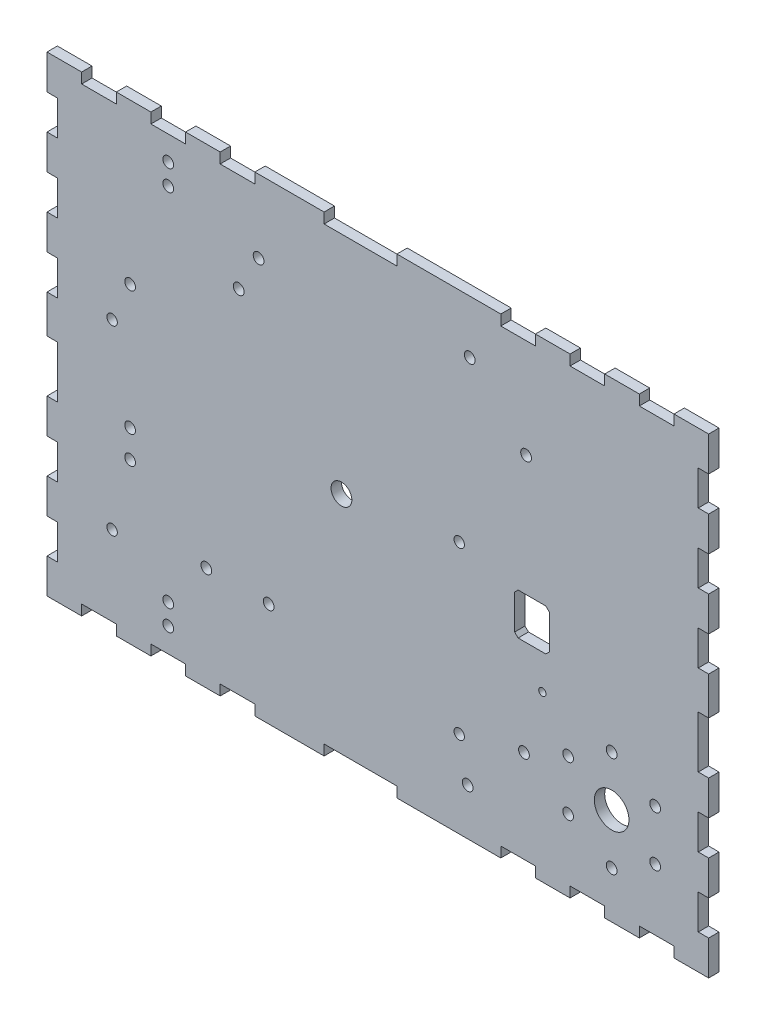
from build123d import *

# Parameters (mm, degrees)
SKETCH2_W           = 191
SKETCH2_H           = 136
SKETCH2_R           = 1.55
SKETCH2_R_2         = 1.549999948
SKETCH2_R_3         = 1.5
BOSS_EXTRUDE1_DEPTH = 3
CUT_EXTRUDE1_REACH  = 236.491
SKETCH3_W           = 10
SKETCH3_H           = 3
SKETCH3_W_2         = 21
CUT_EXTRUDE2_REACH  = 236.491
SKETCH4_W           = 3
SKETCH4_H           = 10
SKETCH4_H_2         = 15
CUT_EXTRUDE3_REACH  = 236.491
SKETCH8_R           = 5
CUT_EXTRUDE4_REACH  = 236.491
SKETCH9_R           = 3
CUT_EXTRUDE5_REACH  = 236.491
SKETCH10_R          = 1.55
CUT_EXTRUDE6_REACH  = 236.491
SKETCH11_R          = 1.05
SKETCH11_W          = 10
SKETCH11_H          = 12
CHAMFER1_SIZE       = 1


with BuildPart() as part:
    # Sketch2 → Boss-Extrude1 (new body)
    with BuildSketch(Plane.XY):
        with Locations((95.5, 68)):
            Rectangle(SKETCH2_W, SKETCH2_H)
        with Locations((35, 16)):
            Circle(SKETCH2_R, mode=Mode.SUBTRACT)
        with Locations((35, 10)):
            Circle(SKETCH2_R, mode=Mode.SUBTRACT)
        with Locations((24, 46.069195574)):
            Circle(SKETCH2_R, mode=Mode.SUBTRACT)
        with Locations((24, 54.069195574)):
            Circle(SKETCH2_R, mode=Mode.SUBTRACT)
        with Locations((24, 89.930804426)):
            Circle(SKETCH2_R, mode=Mode.SUBTRACT)
        with Locations((35, 120)):
            Circle(SKETCH2_R, mode=Mode.SUBTRACT)
        with Locations((35, 126)):
            Circle(SKETCH2_R, mode=Mode.SUBTRACT)
        with Locations((175.557368355, 35.25)):
            Circle(SKETCH2_R_2, mode=Mode.SUBTRACT)
        with Locations((163, 42.5)):
            Circle(SKETCH2_R_2, mode=Mode.SUBTRACT)
        with Locations((150.442631645, 35.25)):
            Circle(SKETCH2_R_2, mode=Mode.SUBTRACT)
        with Locations((150.442631645, 20.75)):
            Circle(SKETCH2_R_2, mode=Mode.SUBTRACT)
        with Locations((163, 13.5)):
            Circle(SKETCH2_R_2, mode=Mode.SUBTRACT)
        with Locations((175.557368355, 20.75)):
            Circle(SKETCH2_R_2, mode=Mode.SUBTRACT)
        with Locations((18.8, 78.5)):
            Circle(SKETCH2_R_3, mode=Mode.SUBTRACT)
        with Locations((18.8, 26)):
            Circle(SKETCH2_R_3, mode=Mode.SUBTRACT)
        with Locations((119, 73)):
            Circle(SKETCH2_R_3, mode=Mode.SUBTRACT)
        with Locations((119, 25)):
            Circle(SKETCH2_R_3, mode=Mode.SUBTRACT)
    extrude(amount=BOSS_EXTRUDE1_DEPTH)

    # Sketch3 → Cut-Extrude1 (cut, up to next)
    with BuildSketch(Plane.XY.offset(3), mode=Mode.PRIVATE) as cut_extrude1_sk1:
        with Locations((176, 1.5)):
            Rectangle(SKETCH3_W, SKETCH3_H)
    cut_extrude1_tool1 = extrude(cut_extrude1_sk1.sketch, amount=-CUT_EXTRUDE1_REACH, mode=Mode.PRIVATE) & part.part
    # Sketch3 → Cut-Extrude1 (cut, up to next)
    with BuildSketch(Plane.XY.offset(3), mode=Mode.PRIVATE) as cut_extrude1_sk2:
        with Locations((156, 1.5)):
            Rectangle(SKETCH3_W, SKETCH3_H)
    cut_extrude1_tool2 = extrude(cut_extrude1_sk2.sketch, amount=-CUT_EXTRUDE1_REACH, mode=Mode.PRIVATE) & part.part
    # Sketch3 → Cut-Extrude1 (cut, up to next)
    with BuildSketch(Plane.XY.offset(3), mode=Mode.PRIVATE) as cut_extrude1_sk3:
        with Locations((136, 1.5)):
            Rectangle(SKETCH3_W, SKETCH3_H)
    cut_extrude1_tool3 = extrude(cut_extrude1_sk3.sketch, amount=-CUT_EXTRUDE1_REACH, mode=Mode.PRIVATE) & part.part
    # Sketch3 → Cut-Extrude1 (cut, up to next)
    with BuildSketch(Plane.XY.offset(3), mode=Mode.PRIVATE) as cut_extrude1_sk4:
        with Locations((90.5, 1.5)):
            Rectangle(SKETCH3_W_2, SKETCH3_H)
    cut_extrude1_tool4 = extrude(cut_extrude1_sk4.sketch, amount=-CUT_EXTRUDE1_REACH, mode=Mode.PRIVATE) & part.part
    # Sketch3 → Cut-Extrude1 (cut, up to next)
    with BuildSketch(Plane.XY.offset(3), mode=Mode.PRIVATE) as cut_extrude1_sk5:
        with Locations((55, 1.5)):
            Rectangle(SKETCH3_W, SKETCH3_H)
    cut_extrude1_tool5 = extrude(cut_extrude1_sk5.sketch, amount=-CUT_EXTRUDE1_REACH, mode=Mode.PRIVATE) & part.part
    # Sketch3 → Cut-Extrude1 (cut, up to next)
    with BuildSketch(Plane.XY.offset(3), mode=Mode.PRIVATE) as cut_extrude1_sk6:
        with Locations((35, 1.5)):
            Rectangle(SKETCH3_W, SKETCH3_H)
    cut_extrude1_tool6 = extrude(cut_extrude1_sk6.sketch, amount=-CUT_EXTRUDE1_REACH, mode=Mode.PRIVATE) & part.part
    # Sketch3 → Cut-Extrude1 (cut, up to next)
    with BuildSketch(Plane.XY.offset(3), mode=Mode.PRIVATE) as cut_extrude1_sk7:
        with Locations((15, 1.5)):
            Rectangle(SKETCH3_W, SKETCH3_H)
    cut_extrude1_tool7 = extrude(cut_extrude1_sk7.sketch, amount=-CUT_EXTRUDE1_REACH, mode=Mode.PRIVATE) & part.part
    cut_extrude1_1 = cut_extrude1_tool1.solids().sort_by_distance((176, 1.5, 3))[0]
    add(cut_extrude1_1, mode=Mode.SUBTRACT)
    cut_extrude1_2 = cut_extrude1_tool2.solids().sort_by_distance((156, 1.5, 3))[0]
    add(cut_extrude1_2, mode=Mode.SUBTRACT)
    cut_extrude1_3 = cut_extrude1_tool3.solids().sort_by_distance((136, 1.5, 3))[0]
    add(cut_extrude1_3, mode=Mode.SUBTRACT)
    cut_extrude1_4 = cut_extrude1_tool4.solids().sort_by_distance((90.5, 1.5, 3))[0]
    add(cut_extrude1_4, mode=Mode.SUBTRACT)
    cut_extrude1_5 = cut_extrude1_tool5.solids().sort_by_distance((55, 1.5, 3))[0]
    add(cut_extrude1_5, mode=Mode.SUBTRACT)
    cut_extrude1_6 = cut_extrude1_tool6.solids().sort_by_distance((35, 1.5, 3))[0]
    add(cut_extrude1_6, mode=Mode.SUBTRACT)
    cut_extrude1_7 = cut_extrude1_tool7.solids().sort_by_distance((15, 1.5, 3))[0]
    add(cut_extrude1_7, mode=Mode.SUBTRACT)
    cut_extrude1 = cut_extrude1_1 + cut_extrude1_2 + cut_extrude1_3 + cut_extrude1_4 + cut_extrude1_5 + cut_extrude1_6 + cut_extrude1_7  # Cut-Extrude1 as one shape, for the pattern or mirror that repeats it

    # Mirror1: Cut-Extrude1 across plane
    add(cut_extrude1.mirror(Plane.ZX.offset(68)), mode=Mode.SUBTRACT)

    # Sketch4 → Cut-Extrude2 (cut, up to next)
    with BuildSketch(Plane.XY.offset(3), mode=Mode.PRIVATE) as cut_extrude2_sk1:
        with Locations((1.5, 121)):
            Rectangle(SKETCH4_W, SKETCH4_H)
    cut_extrude2_tool1 = extrude(cut_extrude2_sk1.sketch, amount=-CUT_EXTRUDE2_REACH, mode=Mode.PRIVATE) & part.part
    # Sketch4 → Cut-Extrude2 (cut, up to next)
    with BuildSketch(Plane.XY.offset(3), mode=Mode.PRIVATE) as cut_extrude2_sk2:
        with Locations((1.5, 101)):
            Rectangle(SKETCH4_W, SKETCH4_H)
    cut_extrude2_tool2 = extrude(cut_extrude2_sk2.sketch, amount=-CUT_EXTRUDE2_REACH, mode=Mode.PRIVATE) & part.part
    # Sketch4 → Cut-Extrude2 (cut, up to next)
    with BuildSketch(Plane.XY.offset(3), mode=Mode.PRIVATE) as cut_extrude2_sk3:
        with Locations((1.5, 81)):
            Rectangle(SKETCH4_W, SKETCH4_H)
    cut_extrude2_tool3 = extrude(cut_extrude2_sk3.sketch, amount=-CUT_EXTRUDE2_REACH, mode=Mode.PRIVATE) & part.part
    # Sketch4 → Cut-Extrude2 (cut, up to next)
    with BuildSketch(Plane.XY.offset(3), mode=Mode.PRIVATE) as cut_extrude2_sk4:
        with Locations((1.5, 15)):
            Rectangle(SKETCH4_W, SKETCH4_H)
    cut_extrude2_tool4 = extrude(cut_extrude2_sk4.sketch, amount=-CUT_EXTRUDE2_REACH, mode=Mode.PRIVATE) & part.part
    # Sketch4 → Cut-Extrude2 (cut, up to next)
    with BuildSketch(Plane.XY.offset(3), mode=Mode.PRIVATE) as cut_extrude2_sk5:
        with Locations((1.5, 35)):
            Rectangle(SKETCH4_W, SKETCH4_H)
    cut_extrude2_tool5 = extrude(cut_extrude2_sk5.sketch, amount=-CUT_EXTRUDE2_REACH, mode=Mode.PRIVATE) & part.part
    # Sketch4 → Cut-Extrude2 (cut, up to next)
    with BuildSketch(Plane.XY.offset(3), mode=Mode.PRIVATE) as cut_extrude2_sk6:
        with Locations((1.5, 57.5)):
            Rectangle(SKETCH4_W, SKETCH4_H_2)
    cut_extrude2_tool6 = extrude(cut_extrude2_sk6.sketch, amount=-CUT_EXTRUDE2_REACH, mode=Mode.PRIVATE) & part.part
    cut_extrude2_1 = cut_extrude2_tool1.solids().sort_by_distance((1.5, 121, 3))[0]
    add(cut_extrude2_1, mode=Mode.SUBTRACT)
    cut_extrude2_2 = cut_extrude2_tool2.solids().sort_by_distance((1.5, 101, 3))[0]
    add(cut_extrude2_2, mode=Mode.SUBTRACT)
    cut_extrude2_3 = cut_extrude2_tool3.solids().sort_by_distance((1.5, 81, 3))[0]
    add(cut_extrude2_3, mode=Mode.SUBTRACT)
    cut_extrude2_4 = cut_extrude2_tool4.solids().sort_by_distance((1.5, 15, 3))[0]
    add(cut_extrude2_4, mode=Mode.SUBTRACT)
    cut_extrude2_5 = cut_extrude2_tool5.solids().sort_by_distance((1.5, 35, 3))[0]
    add(cut_extrude2_5, mode=Mode.SUBTRACT)
    cut_extrude2_6 = cut_extrude2_tool6.solids().sort_by_distance((1.5, 57.5, 3))[0]
    add(cut_extrude2_6, mode=Mode.SUBTRACT)
    cut_extrude2 = cut_extrude2_1 + cut_extrude2_2 + cut_extrude2_3 + cut_extrude2_4 + cut_extrude2_5 + cut_extrude2_6  # Cut-Extrude2 as one shape, for the pattern or mirror that repeats it

    # Mirror2: Cut-Extrude2 across plane
    add(cut_extrude2.mirror(Plane(origin=(95.5, 0, 0), x_dir=(0, 0, 1), z_dir=(1, 0, 0))), mode=Mode.SUBTRACT)

    # Sketch8 → Cut-Extrude3 (cut, up to next)
    with BuildSketch(Plane(origin=(0, 0, 0), x_dir=(-1, 0, 0), z_dir=(0, 0, -1)), mode=Mode.PRIVATE) as cut_extrude3_sk1:
        with Locations((-163, 28)):
            Circle(SKETCH8_R)
    cut_extrude3_tool1 = extrude(cut_extrude3_sk1.sketch, amount=-CUT_EXTRUDE3_REACH, mode=Mode.PRIVATE) & part.part
    add(cut_extrude3_tool1.solids().sort_by_distance((163, 28, 0))[0], mode=Mode.SUBTRACT)

    # Sketch9 → Cut-Extrude4 (cut, up to next)
    with BuildSketch(Plane.XY.offset(3), mode=Mode.PRIVATE) as cut_extrude4_sk1:
        with Locations((85, 68)):
            Circle(SKETCH9_R)
    cut_extrude4_tool1 = extrude(cut_extrude4_sk1.sketch, amount=-CUT_EXTRUDE4_REACH, mode=Mode.PRIVATE) & part.part
    add(cut_extrude4_tool1.solids().sort_by_distance((85, 68, 3))[0], mode=Mode.SUBTRACT)

    # Sketch10 → Cut-Extrude5 (cut, up to next)
    with BuildSketch(Plane.XY.offset(3), mode=Mode.PRIVATE) as cut_extrude5_sk1:
        with Locations((61.086070947, 114.989325612)):
            Circle(SKETCH10_R)
    cut_extrude5_tool1 = extrude(cut_extrude5_sk1.sketch, amount=-CUT_EXTRUDE5_REACH, mode=Mode.PRIVATE) & part.part
    # Sketch10 → Cut-Extrude5 (cut, up to next)
    with BuildSketch(Plane.XY.offset(3), mode=Mode.PRIVATE) as cut_extrude5_sk2:
        with Locations((55.342481492, 104.453141285)):
            Circle(SKETCH10_R)
    cut_extrude5_tool2 = extrude(cut_extrude5_sk2.sketch, amount=-CUT_EXTRUDE5_REACH, mode=Mode.PRIVATE) & part.part
    # Sketch10 → Cut-Extrude5 (cut, up to next)
    with BuildSketch(Plane.XY.offset(3), mode=Mode.PRIVATE) as cut_extrude5_sk3:
        with Locations((138.302074071, 104.36707814)):
            Circle(SKETCH10_R)
    cut_extrude5_tool3 = extrude(cut_extrude5_sk3.sketch, amount=-CUT_EXTRUDE5_REACH, mode=Mode.PRIVATE) & part.part
    # Sketch10 → Cut-Extrude5 (cut, up to next)
    with BuildSketch(Plane.XY.offset(3), mode=Mode.PRIVATE) as cut_extrude5_sk4:
        with Locations((122.038618104, 120.630534107)):
            Circle(SKETCH10_R)
    cut_extrude5_tool4 = extrude(cut_extrude5_sk4.sketch, amount=-CUT_EXTRUDE5_REACH, mode=Mode.PRIVATE) & part.part
    # Sketch10 → Cut-Extrude5 (cut, up to next)
    with BuildSketch(Plane.XY.offset(3), mode=Mode.PRIVATE) as cut_extrude5_sk5:
        with Locations((64, 30)):
            Circle(SKETCH10_R)
    cut_extrude5_tool5 = extrude(cut_extrude5_sk5.sketch, amount=-CUT_EXTRUDE5_REACH, mode=Mode.PRIVATE) & part.part
    # Sketch10 → Cut-Extrude5 (cut, up to next)
    with BuildSketch(Plane.XY.offset(3), mode=Mode.PRIVATE) as cut_extrude5_sk6:
        with Locations((46, 30)):
            Circle(SKETCH10_R)
    cut_extrude5_tool6 = extrude(cut_extrude5_sk6.sketch, amount=-CUT_EXTRUDE5_REACH, mode=Mode.PRIVATE) & part.part
    # Sketch10 → Cut-Extrude5 (cut, up to next)
    with BuildSketch(Plane.XY.offset(3), mode=Mode.PRIVATE) as cut_extrude5_sk7:
        with Locations((137.698811825, 29.728755384)):
            Circle(SKETCH10_R)
    cut_extrude5_tool7 = extrude(cut_extrude5_sk7.sketch, amount=-CUT_EXTRUDE5_REACH, mode=Mode.PRIVATE) & part.part
    # Sketch10 → Cut-Extrude5 (cut, up to next)
    with BuildSketch(Plane.XY.offset(3), mode=Mode.PRIVATE) as cut_extrude5_sk8:
        with Locations((121.435355858, 13.465299417)):
            Circle(SKETCH10_R)
    cut_extrude5_tool8 = extrude(cut_extrude5_sk8.sketch, amount=-CUT_EXTRUDE5_REACH, mode=Mode.PRIVATE) & part.part
    add(cut_extrude5_tool1.solids().sort_by_distance((61.086071, 114.989326, 3))[0], mode=Mode.SUBTRACT)
    add(cut_extrude5_tool2.solids().sort_by_distance((55.342481, 104.453141, 3))[0], mode=Mode.SUBTRACT)
    add(cut_extrude5_tool3.solids().sort_by_distance((138.302074, 104.367078, 3))[0], mode=Mode.SUBTRACT)
    add(cut_extrude5_tool4.solids().sort_by_distance((122.038618, 120.630534, 3))[0], mode=Mode.SUBTRACT)
    add(cut_extrude5_tool5.solids().sort_by_distance((64, 30, 3))[0], mode=Mode.SUBTRACT)
    add(cut_extrude5_tool6.solids().sort_by_distance((46, 30, 3))[0], mode=Mode.SUBTRACT)
    add(cut_extrude5_tool7.solids().sort_by_distance((137.698812, 29.728755, 3))[0], mode=Mode.SUBTRACT)
    add(cut_extrude5_tool8.solids().sort_by_distance((121.435356, 13.465299, 3))[0], mode=Mode.SUBTRACT)

    # Sketch11 → Cut-Extrude6 (cut, up to next)
    with BuildSketch(Plane.XY.offset(3), mode=Mode.PRIVATE) as cut_extrude6_sk1:
        with Locations((143, 47.5)):
            Circle(SKETCH11_R)
    cut_extrude6_tool1 = extrude(cut_extrude6_sk1.sketch, amount=-CUT_EXTRUDE6_REACH, mode=Mode.PRIVATE) & part.part
    # Sketch11 → Cut-Extrude6 (cut, up to next)
    with BuildSketch(Plane.XY.offset(3), mode=Mode.PRIVATE) as cut_extrude6_sk2:
        with Locations((140, 63.5)):
            Rectangle(SKETCH11_W, SKETCH11_H)
    cut_extrude6_tool2 = extrude(cut_extrude6_sk2.sketch, amount=-CUT_EXTRUDE6_REACH, mode=Mode.PRIVATE) & part.part
    add(cut_extrude6_tool1.solids().sort_by_distance((143, 47.5, 3))[0], mode=Mode.SUBTRACT)
    add(cut_extrude6_tool2.solids().sort_by_distance((140, 63.5, 3))[0], mode=Mode.SUBTRACT)

    # Chamfer1
    chamfer1_edges = [part.edges().sort_by_distance(p)[0] for p in [
        (135, 69.5, 1.5),
        (145, 69.5, 1.5),
        (145, 57.5, 1.5),
        (135, 57.5, 1.5),
    ]]
    chamfer(chamfer1_edges, length=CHAMFER1_SIZE)


solid = part.part
